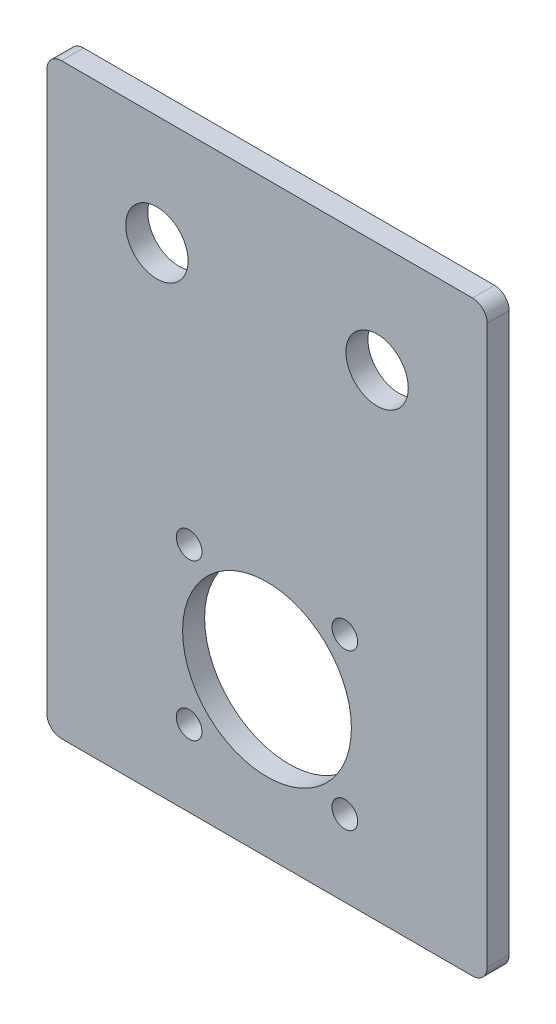
from build123d import *

# Parameters (mm, degrees)
SKETCH_1_W          = 60
SKETCH_1_H          = 80
EXTRUDE_1_DEPTH     = 3
SKETCH_2_R          = 11.5
SKETCH_2_R_2        = 1.75
SKETCH_2_R_3        = 4.25
CUT_EXTRUDE_1_DEPTH = 4
FILLET_1_R          = 2


with BuildPart() as part:
    # 草图1 → 凸台-拉伸1 (new body)
    with BuildSketch(Plane.XY):
        with Locations((30, 40)):
            Rectangle(SKETCH_1_W, SKETCH_1_H)
    extrude(amount=EXTRUDE_1_DEPTH)

    # 草图2 → 切除-拉伸1 (cut, through all)
    with BuildSketch(Plane.XY.offset(3)):
        with Locations((30, 21)):
            Circle(SKETCH_2_R)
        with Locations((19.393398282, 31.606601718)):
            Circle(SKETCH_2_R_2)
        with Locations((40.606601718, 31.606601718)):
            Circle(SKETCH_2_R_2)
        with Locations((40.606601718, 10.393398282)):
            Circle(SKETCH_2_R_2)
        with Locations((19.393398282, 10.393398282)):
            Circle(SKETCH_2_R_2)
        with Locations((15, 65)):
            Circle(SKETCH_2_R_3)
        with Locations((45, 65)):
            Circle(SKETCH_2_R_3)
    extrude(amount=-CUT_EXTRUDE_1_DEPTH, mode=Mode.SUBTRACT)

    # 圆角1
    fillet_1_edges = [part.edges().sort_by_distance(p)[0] for p in [
        (0, 80, 1.5),
        (60, 80, 1.5),
        (60, 0, 1.5),
        (0, 0, 1.5),
    ]]
    fillet(fillet_1_edges, radius=FILLET_1_R)


solid = part.part
